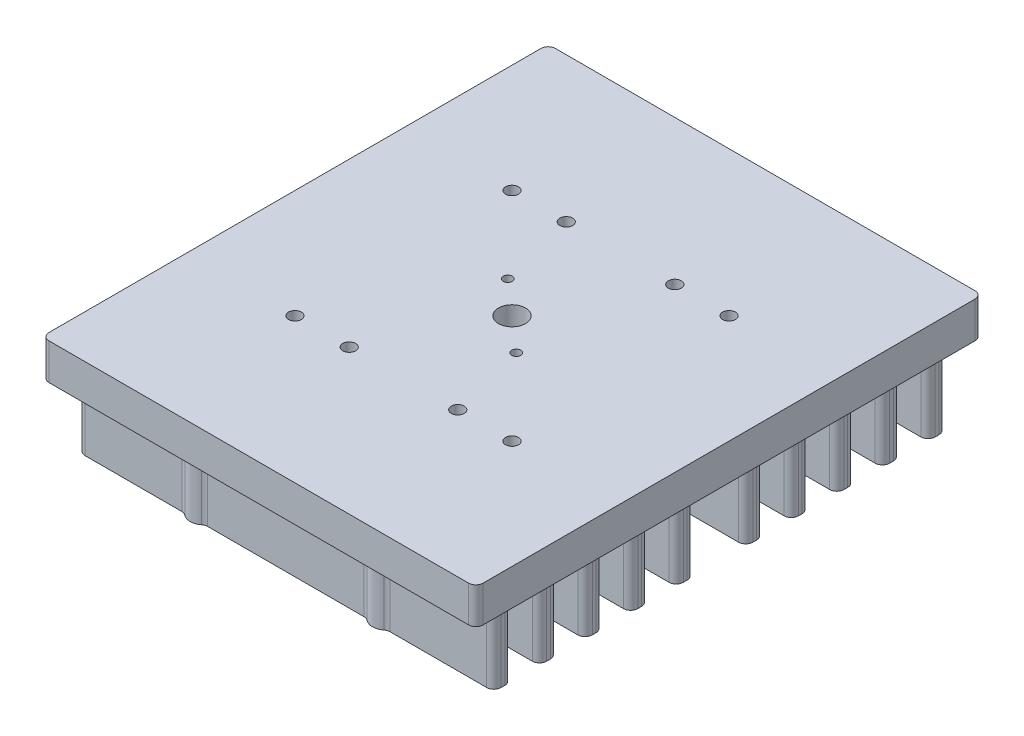
from build123d import *

# Parameters (mm, degrees)
SKETCH1_W                 = 76.2
SKETCH1_H                 = 88.9
BOSS_EXTRUDE1_DEPTH       = 6.35
F_4_40_TAPPED_HOLE1_D     = 2.2606
M2X0_4_TAPPED_HOLE1_D     = 1.6
SKETCH6_R                 = 2.38125
BOSS_EXTRUDE2_DEPTH       = 12.7
SKETCH9_W                 = 73.025
SKETCH9_H                 = 3.175
BOSS_EXTRUDE3_DEPTH       = 12.7
F_6_32_TAPPED_HOLE1_D     = 2.7051
F_6_32_TAPPED_HOLE1_DEPTH = 9.398
F_6_32_TAPPED_HOLE1_TIP   = 0.81269403
FILLET1_R                 = 1.27
SKETCH10_R                = 2.38125
CUT_EXTRUDE1_DEPTH        = 20.05
F_4_40_TAPPED_HOLE2_D     = 2.2606
F_4_40_TAPPED_HOLE2_DEPTH = 8.763
F_4_40_TAPPED_HOLE2_TIP   = 0.679152758


with BuildPart() as part:
    # Sketch1 → Boss-Extrude1 (new body)
    with BuildSketch(Plane(origin=(0, 0, 0), x_dir=(1, 0, 0), z_dir=(0, 1, 0))):
        Rectangle(SKETCH1_W, SKETCH1_H)
    extrude(amount=BOSS_EXTRUDE1_DEPTH)

    # #4-40 Tapped Hole1 (through all)
    with Locations(Plane(origin=(0, 6.35, 0), x_dir=(1, 0, 0), z_dir=(0, 1, 0))):
        with Locations((19.05, -19.05), (-19.05, 19.05), (-19.05, -19.05), (19.05, 19.05)):
            Hole(F_4_40_TAPPED_HOLE1_D / 2)

    # M2x0.4 Tapped Hole1 (through all)
    with Locations(Plane(origin=(0, 6.35, 0), x_dir=(1, 0, 0), z_dir=(0, 1, 0))):
        with Locations((-6, 5.25), (6, -5.25)):
            Hole(M2X0_4_TAPPED_HOLE1_D / 2)

    # Sketch6 → Boss-Extrude2 (add)
    with BuildSketch(Plane.XZ):
        with Locations(Location((-16, 38.1, 0), (0, 0, 90))):  # turned: the seam where the file's is
            Circle(SKETCH6_R)
        with Locations(Location((16, 38.1, 0), (0, 0, 90))):  # turned: the seam where the file's is
            Circle(SKETCH6_R)
        with Locations(Location((-16, 6.1, 0), (0, 0, 90))):  # turned: the seam where the file's is
            Circle(SKETCH6_R)
        with Locations(Location((16, 6.1, 0), (0, 0, 90))):  # turned: the seam where the file's is
            Circle(SKETCH6_R)
        with Locations(Location((16, -6.1, 0), (0, 0, 90))):  # turned: the seam where the file's is
            Circle(SKETCH6_R)
        with Locations(Location((-16, -6.1, 0), (0, 0, 90))):  # turned: the seam where the file's is
            Circle(SKETCH6_R)
        with Locations(Location((16, -38.1, 0), (0, 0, 90))):  # turned: the seam where the file's is
            Circle(SKETCH6_R)
        with Locations(Location((-16, -38.1, 0), (0, 0, 90))):  # turned: the seam where the file's is
            Circle(SKETCH6_R)
    extrude(amount=BOSS_EXTRUDE2_DEPTH)

    # Sketch9 → Boss-Extrude3 (add)
    with BuildSketch(Plane.XZ):
        with Locations((0, 38.1)):
            Rectangle(SKETCH9_W, SKETCH9_H)
        with Locations((0, 30.1)):
            Rectangle(SKETCH9_W, SKETCH9_H)
        with Locations((0, 22.1)):
            Rectangle(SKETCH9_W, SKETCH9_H)
        with Locations((0, 14.1)):
            Rectangle(SKETCH9_W, SKETCH9_H)
        with Locations((0, 6.1)):
            Rectangle(SKETCH9_W, SKETCH9_H)
        with Locations((0, -6.1)):
            Rectangle(SKETCH9_W, SKETCH9_H)
        with Locations((0, -14.1)):
            Rectangle(SKETCH9_W, SKETCH9_H)
        with Locations((0, -22.1)):
            Rectangle(SKETCH9_W, SKETCH9_H)
        with Locations((0, -30.1)):
            Rectangle(SKETCH9_W, SKETCH9_H)
        with Locations((0, -38.1)):
            Rectangle(SKETCH9_W, SKETCH9_H)
    extrude(amount=BOSS_EXTRUDE3_DEPTH)

    # #6-32 Tapped Hole1
    with Locations(Plane(origin=(0, -12.7, 0), x_dir=(-1, 0, 0), z_dir=(0, -1, 0))):
        with Locations((16, -38.1), (-16, -38.1), (-16, 38.1), (16, 38.1), (-16, 6.1), (16, 6.1), (16, -6.1), (-16, -6.1)):
            Hole(F_6_32_TAPPED_HOLE1_D / 2, depth=F_6_32_TAPPED_HOLE1_DEPTH)
            with Locations((0, 0, -(F_6_32_TAPPED_HOLE1_DEPTH + F_6_32_TAPPED_HOLE1_TIP / 2))):  # 118° drill point
                Cone(0, F_6_32_TAPPED_HOLE1_D / 2, F_6_32_TAPPED_HOLE1_TIP, mode=Mode.SUBTRACT)

    # Fillet1
    fillet1_edges = [part.edges().sort_by_distance(p)[0] for p in [
        (-36.5125, -6.35, 31.6875),
        (-36.5125, -6.35, 28.5125),
        (36.5125, -6.35, 28.5125),
        (36.5125, -6.35, 31.6875),
        (-36.5125, -6.35, 23.6875),
        (-36.5125, -6.35, 20.5125),
        (36.5125, -6.35, 20.5125),
        (36.5125, -6.35, 23.6875),
        (-36.5125, -6.35, 15.6875),
        (-36.5125, -6.35, 12.5125),
        (36.5125, -6.35, 12.5125),
        (36.5125, -6.35, 15.6875),
        (-36.5125, -6.35, -12.5125),
        (-36.5125, -6.35, -15.6875),
        (36.5125, -6.35, -15.6875),
        (36.5125, -6.35, -12.5125),
        (17.774878957, -6.35, -7.6875),
        (14.225121043, -6.35, -7.6875),
        (-14.225121043, -6.35, -7.6875),
        (-17.774878957, -6.35, -7.6875),
        (-36.5125, -6.35, -7.6875),
        (14.225121043, -6.35, -4.5125),
        (-14.225121043, -6.35, -4.5125),
        (17.774878957, -6.35, -4.5125),
        (36.5125, -6.35, -4.5125),
        (-17.774878957, -6.35, -4.5125),
        (36.5125, -6.35, -7.6875),
        (-36.5125, -6.35, -4.5125),
        (-36.5125, -6.35, -20.5125),
        (-36.5125, -6.35, -23.6875),
        (36.5125, -6.35, -23.6875),
        (36.5125, -6.35, -20.5125),
        (-36.5125, -6.35, -28.5125),
        (-36.5125, -6.35, -31.6875),
        (36.5125, -6.35, -31.6875),
        (36.5125, -6.35, -28.5125),
        (17.774878957, -6.35, -39.6875),
        (14.225121043, -6.35, -39.6875),
        (-14.225121043, -6.35, -39.6875),
        (-17.774878957, -6.35, -39.6875),
        (-36.5125, -6.35, -39.6875),
        (14.225121043, -6.35, -36.5125),
        (-14.225121043, -6.35, -36.5125),
        (17.774878957, -6.35, -36.5125),
        (36.5125, -6.35, -36.5125),
        (-17.774878957, -6.35, -36.5125),
        (-36.5125, -6.35, -36.5125),
        (36.5125, -6.35, -39.6875),
        (-14.225121043, -6.35, 4.5125),
        (14.225121043, -6.35, 4.5125),
        (-17.774878957, -6.35, 4.5125),
        (-36.5125, -6.35, 4.5125),
        (17.774878957, -6.35, 4.5125),
        (-17.774878957, -6.35, 7.6875),
        (-14.225121043, -6.35, 7.6875),
        (14.225121043, -6.35, 7.6875),
        (17.774878957, -6.35, 7.6875),
        (36.5125, -6.35, 7.6875),
        (-36.5125, -6.35, 7.6875),
        (36.5125, -6.35, 4.5125),
        (38.1, 3.175, 44.45),
        (-38.1, 3.175, 44.45),
        (-38.1, 3.175, -44.45),
        (38.1, 3.175, -44.45),
        (-14.225121043, -6.35, 36.5125),
        (14.225121043, -6.35, 36.5125),
        (-17.774878957, -6.35, 36.5125),
        (-36.5125, -6.35, 36.5125),
        (17.774878957, -6.35, 36.5125),
        (-17.774878957, -6.35, 39.6875),
        (-14.225121043, -6.35, 39.6875),
        (14.225121043, -6.35, 39.6875),
        (17.774878957, -6.35, 39.6875),
        (36.5125, -6.35, 39.6875),
        (-36.5125, -6.35, 39.6875),
        (36.5125, -6.35, 36.5125),
    ]]
    fillet(fillet1_edges, radius=FILLET1_R)

    # Sketch10 → Cut-Extrude1 (cut, through all)
    with BuildSketch(Plane(origin=(0, 6.35, 0), x_dir=(1, 0, 0), z_dir=(0, 1, 0))):
        with Locations(Location((0, 0, 0), (0, 0, 270))):  # turned: the seam where the file's is
            Circle(SKETCH10_R)
    extrude(amount=-CUT_EXTRUDE1_DEPTH, mode=Mode.SUBTRACT)

    # #4-40 Tapped Hole2
    with Locations(Plane(origin=(-33.504228334, 6.35, -53.736749861), x_dir=(1, 0, 0), z_dir=(0, 1, 0))):
        with Locations((43.029228334, -34.686749861), (23.979228334, -34.686749861), (23.979228334, -72.786749861), (43.029228334, -72.786749861)):
            Hole(F_4_40_TAPPED_HOLE2_D / 2, depth=F_4_40_TAPPED_HOLE2_DEPTH)
            with Locations((0, 0, -(F_4_40_TAPPED_HOLE2_DEPTH + F_4_40_TAPPED_HOLE2_TIP / 2))):  # 118° drill point
                Cone(0, F_4_40_TAPPED_HOLE2_D / 2, F_4_40_TAPPED_HOLE2_TIP, mode=Mode.SUBTRACT)


solid = part.part
